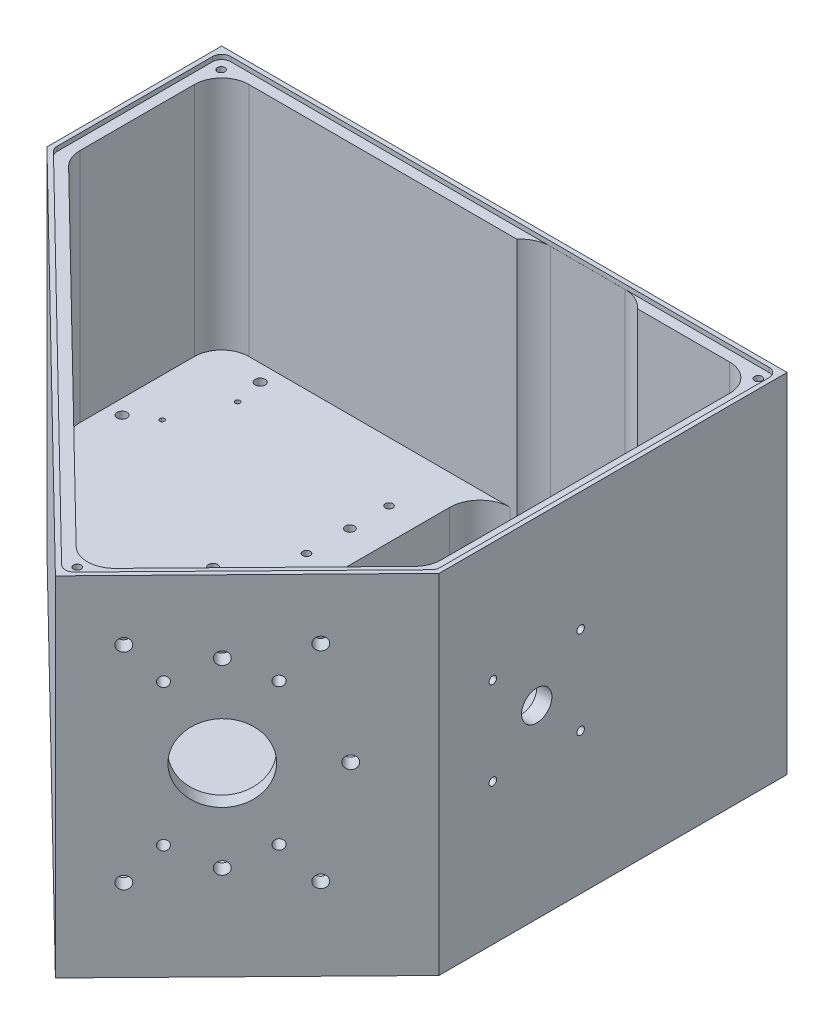
from build123d import *

# Parameters (mm, degrees)
BOSS_EXTRUDE3_DEPTH             = 10
BOSS_EXTRUDE5_DEPTH             = 105
FILLET2_R                       = 9
BOSS_EXTRUDE7_DEPTH             = 25.7
FILLET3_R                       = 10
FILLET4_R                       = 10
CUT_EXTRUDE4_DEPTH              = 1.5
FILLET5_R                       = 3
CUT_EXTRUDE5_DEPTH              = 20
FILLET6_R                       = 10
CUT_EXTRUDE6_REACH              = 188.714
SKETCH13_R                      = 5
M4X0_7_TAPPED_HOLE2_D           = 3.3
M4X0_7_TAPPED_HOLE2_DEPTH       = 5
SM1_TAPPED_HOLE1_D              = 25.4
SM1_TAPPED_HOLE1_DEPTH          = 5
M4X0_7_TAPPED_HOLE1_D           = 3.3
M4X0_7_TAPPED_HOLE1_DEPTH       = 8
M4X0_7_TAPPED_HOLE1_TIP         = 0.991420021
M2X0_4_TAPPED_HOLE1_D           = 1.6
M2X0_4_TAPPED_HOLE1_DEPTH       = 5.2
M2X0_4_TAPPED_HOLE1_TIP         = 0.480688495
M3X0_5_TAPPED_HOLE1_D           = 2.5
M3X0_5_TAPPED_HOLE1_DEPTH       = 7.5
M3X0_5_TAPPED_HOLE1_TIP         = 0.751075774
F_3_0MM_DOWEL_HOLE1_D           = 3
F_3_0MM_DOWEL_HOLE1_DEPTH       = 5.2
F_3_0MM_DOWEL_HOLE1_TIP         = 0.901290929
M3X0_5_TAPPED_HOLE2_D           = 2.5
M3X0_5_TAPPED_HOLE2_DEPTH       = 5
M3X0_5_TAPPED_HOLE3_D           = 2.5
M3X0_5_TAPPED_HOLE3_DEPTH       = 7.5
M3X0_5_TAPPED_HOLE3_TIP         = 0.751075774
F_1_16_0_0625_DOWEL_HOLE1_D     = 1.5875
F_1_16_0_0625_DOWEL_HOLE1_DEPTH = 5.2
F_1_16_0_0625_DOWEL_HOLE1_TIP   = 0.476933116
F_3_0MM_DOWEL_HOLE2_D           = 3
F_3_0MM_DOWEL_HOLE2_DEPTH       = 5.2
F_3_0MM_DOWEL_HOLE2_TIP         = 0.901290929
M3X0_5_TAPPED_HOLE4_D           = 2.5
M3X0_5_TAPPED_HOLE4_DEPTH       = 7.5
M3X0_5_TAPPED_HOLE4_TIP         = 0.751075774
CUT_EXTRUDE7_DEPTH              = 103.5
M5X0_8_TAPPED_HOLE2_D           = 4.2
M5X0_8_TAPPED_HOLE2_DEPTH       = 5
M5X0_8_TAPPED_HOLE3_D           = 4.2
M5X0_8_TAPPED_HOLE3_DEPTH       = 5


with BuildPart() as part:
    # Sketch1 → Boss-Extrude3 (new body)
    with BuildSketch(Plane(origin=(0, 0, 0), x_dir=(1, 0, 0), z_dir=(0, 1, 0))):
        Polygon((-99.454594588, 85.287259619), (-99.454594588, 27.580704883), (24.630684429, -93.704474274), (87.259436127, -29.629818302), (87.259436127, 85.287259619), align=None)
    extrude(amount=BOSS_EXTRUDE3_DEPTH)

    # Sketch6 → Boss-Extrude5 (add)
    with BuildSketch(Plane(origin=(0, 10, 0), x_dir=(1, 0, 0), z_dir=(0, 1, 0))):
        Polygon((-99.454594588, 85.287259619), (-99.454594588, 27.580704883), (24.630684429, -93.704474274), (87.259436127, -29.629818302), (87.259436127, 85.287259619), align=None)
        Polygon((82.259436127, 80.287259619), (-94.454594588, 80.287259619), (-94.454594588, 29.68527495), (24.549996611, -86.63386684), (82.259436127, -27.592094762), align=None, mode=Mode.SUBTRACT)
    extrude(amount=BOSS_EXTRUDE5_DEPTH)

    # Fillet2
    fillet2_edges = [part.edges().sort_by_distance(p)[0] for p in [
        (82.259436127, 62.5, -80.287259619),
        (-94.454594588, 62.5, -80.287259619),
        (-94.454594588, 62.5, -29.68527495),
        (24.549996611, 62.5, 86.63386684),
        (82.259436127, 62.5, 27.592094762),
    ]]
    fillet(fillet2_edges, radius=FILLET2_R)

    # Sketch9 → Boss-Extrude7 (add)
    with BuildSketch(Plane(origin=(0, 10, 0), x_dir=(1, 0, 0), z_dir=(0, 1, 0))):
        Polygon((-9.164109107, 80.287259619), (-9.164109107, 16.274353327), (-44.132452564, -19.501301083), (-96.380135247, 31.56736399), (-96.380135247, 80.287259619), align=None)
    extrude(amount=BOSS_EXTRUDE7_DEPTH)

    # Fillet3
    fillet3_edges = [part.edges().sort_by_distance(p)[0] for p in [
        (-44.132452564, 22.85, 19.501301083),
    ]]
    fillet(fillet3_edges, radius=FILLET3_R)

    # Fillet4
    fillet4_edges = [part.edges().sort_by_distance(p)[0] for p in [
        (-9.164109107, 22.85, -80.287259619),
    ]]
    fillet(fillet4_edges, radius=FILLET4_R)

    # Sketch10 → Cut-Extrude4 (cut)
    with BuildSketch(Plane(origin=(0, 115, 0), x_dir=(1, 0, 0), z_dir=(0, 1, 0))):
        Polygon((-97.954594588, 28.212075903), (24.606478083, -91.583292044), (85.759436127, -29.01850124), (85.759436127, 83.787259619), (-97.954594588, 83.787259619), align=None)
    extrude(amount=-CUT_EXTRUDE4_DEPTH, mode=Mode.SUBTRACT)

    # Fillet5
    fillet5_edges = [part.edges().sort_by_distance(p)[0] for p in [
        (-97.954594588, 114.25, -28.212075903),
        (-97.954594588, 114.25, -83.787259619),
        (85.759436127, 114.25, -83.787259619),
        (85.759436127, 114.25, 29.01850124),
        (24.606478083, 114.25, 91.583292044),
    ]]
    fillet(fillet5_edges, radius=FILLET5_R)

    # Sketch12 → Cut-Extrude5 (cut)
    with BuildSketch(Plane.XZ):
        Polygon((-86.029052321, -30.238498612), (-44.83183875, 10.029061474), (-15.886944756, -19.584080646), (-15.886944756, -74.947835353), (-86.029052321, -74.947835353), align=None)
    extrude(amount=-CUT_EXTRUDE5_DEPTH, mode=Mode.SUBTRACT)

    # Fillet6
    fillet6_edges = [part.edges().sort_by_distance(p)[0] for p in [
        (-86.029052321, 10, -74.947835353),
        (-86.029052321, 10, -30.238498612),
        (-44.83183875, 10, 10.029061474),
        (-15.886944756, 10, -19.584080646),
        (-15.886944756, 10, -74.947835353),
    ]]
    fillet(fillet6_edges, radius=FILLET6_R)

    # Sketch13 → Cut-Extrude6 (cut, up to next)
    with BuildSketch(Plane(origin=(87.259436127, 0, 0), x_dir=(0, 0, -1), z_dir=(1, 0, 0)), mode=Mode.PRIVATE) as cut_extrude6_sk1:
        with Locations((2.612649558, 61.1)):
            Circle(SKETCH13_R)
    cut_extrude6_tool1 = extrude(cut_extrude6_sk1.sketch, amount=-CUT_EXTRUDE6_REACH, mode=Mode.PRIVATE) & part.part
    add(cut_extrude6_tool1.solids().sort_by_distance((87.259436, 61.1, -2.61265))[0], mode=Mode.SUBTRACT)

    # M4x0.7 Tapped Hole2
    with Locations(Plane(origin=(59.436420011, 0, 58.095181851), x_dir=(0.698991962, 0, -0.715129525), z_dir=(0.715129525, 0, 0.698991962))):
        with Locations((2.431115729, 37.767314098), (2.431115729, 84.532685902), (-24.568884271, 84.532685902), (-24.568884271, 37.767314098)):
            Hole(M4X0_7_TAPPED_HOLE2_D / 2, depth=M4X0_7_TAPPED_HOLE2_DEPTH)

    # SM1 Tapped Hole1
    with Locations(Plane(origin=(59.436420011, 0, 58.095181851), x_dir=(0.698991962, 0, -0.715129525), z_dir=(0.715129525, 0, 0.698991962))):
        with Locations((-10.825880291, 61.15)):
            Hole(SM1_TAPPED_HOLE1_D / 2, depth=SM1_TAPPED_HOLE1_DEPTH)

    # M4x0.7 Tapped Hole1
    with Locations(Plane(origin=(0, 35.7, 0), x_dir=(1, 0, 0), z_dir=(0, 1, 0))):
        with Locations((-76.250393956, 74.820995384), (-89.615612831, 42.554502711)):
            Hole(M4X0_7_TAPPED_HOLE1_D / 2, depth=M4X0_7_TAPPED_HOLE1_DEPTH)
            with Locations((0, 0, -(M4X0_7_TAPPED_HOLE1_DEPTH + M4X0_7_TAPPED_HOLE1_TIP / 2))):  # 118° drill point
                Cone(0, M4X0_7_TAPPED_HOLE1_D / 2, M4X0_7_TAPPED_HOLE1_TIP, mode=Mode.SUBTRACT)

    # M2x0.4 Tapped Hole1
    with Locations(Plane(origin=(0, 10, 0), x_dir=(1, 0, 0), z_dir=(0, 1, 0))):
        with Locations((5.789584185, 54.312649558), (25.789584185, 54.312649558), (5.789584185, 34.312649558), (25.789584185, 34.312649558)):
            Hole(M2X0_4_TAPPED_HOLE1_D / 2, depth=M2X0_4_TAPPED_HOLE1_DEPTH)
            with Locations((0, 0, -(M2X0_4_TAPPED_HOLE1_DEPTH + M2X0_4_TAPPED_HOLE1_TIP / 2))):  # 118° drill point
                Cone(0, M2X0_4_TAPPED_HOLE1_D / 2, M2X0_4_TAPPED_HOLE1_TIP, mode=Mode.SUBTRACT)

    # M3x0.5 Tapped Hole1
    with Locations(Plane(origin=(0, 10, 0), x_dir=(1, 0, 0), z_dir=(0, 1, 0))):
        with Locations((53.486513194, 36.740704463), (53.486513194, 17.338730644)):
            Hole(M3X0_5_TAPPED_HOLE1_D / 2, depth=M3X0_5_TAPPED_HOLE1_DEPTH)
            with Locations((0, 0, -(M3X0_5_TAPPED_HOLE1_DEPTH + M3X0_5_TAPPED_HOLE1_TIP / 2))):  # 118° drill point
                Cone(0, M3X0_5_TAPPED_HOLE1_D / 2, M3X0_5_TAPPED_HOLE1_TIP, mode=Mode.SUBTRACT)

    # Ø3.0mm Dowel Hole1
    with Locations(Plane(origin=(0, 10, 0), x_dir=(1, 0, 0), z_dir=(0, 1, 0))):
        with Locations((73.986513194, 2.338730644), (53.486513194, 53.338730644)):
            Hole(F_3_0MM_DOWEL_HOLE1_D / 2, depth=F_3_0MM_DOWEL_HOLE1_DEPTH)
            with Locations((0, 0, -(F_3_0MM_DOWEL_HOLE1_DEPTH + F_3_0MM_DOWEL_HOLE1_TIP / 2))):  # 118° drill point
                Cone(0, F_3_0MM_DOWEL_HOLE1_D / 2, F_3_0MM_DOWEL_HOLE1_TIP, mode=Mode.SUBTRACT)

    # M3x0.5 Tapped Hole2
    with Locations(Plane(origin=(87.259436127, 0, 0), x_dir=(0, 0, -1), z_dir=(1, 0, 0))):
        with Locations((17.112649558, 75.6), (17.112649558, 46.6), (-11.887350442, 46.6), (-11.887350442, 75.6)):
            Hole(M3X0_5_TAPPED_HOLE2_D / 2, depth=M3X0_5_TAPPED_HOLE2_DEPTH)

    # M3x0.5 Tapped Hole3
    with Locations(Plane(origin=(0, 35.7, 0), x_dir=(1, 0, 0), z_dir=(0, 1, 0))):
        with Locations((-19.601854144, 60.718472071), (-19.601854144, 33.456137846)):
            Hole(M3X0_5_TAPPED_HOLE3_D / 2, depth=M3X0_5_TAPPED_HOLE3_DEPTH)
            with Locations((0, 0, -(M3X0_5_TAPPED_HOLE3_DEPTH + M3X0_5_TAPPED_HOLE3_TIP / 2))):  # 118° drill point
                Cone(0, M3X0_5_TAPPED_HOLE3_D / 2, M3X0_5_TAPPED_HOLE3_TIP, mode=Mode.SUBTRACT)

    # 1/16 (0.0625) Dowel Hole1
    with Locations(Plane(origin=(0, 35.7, 0), x_dir=(1, 0, 0), z_dir=(0, 1, 0))):
        with Locations((-81.65008966, 47.846563072), (-74.359970274, 65.446468166)):
            Hole(F_1_16_0_0625_DOWEL_HOLE1_D / 2, depth=F_1_16_0_0625_DOWEL_HOLE1_DEPTH)
            with Locations((0, 0, -(F_1_16_0_0625_DOWEL_HOLE1_DEPTH + F_1_16_0_0625_DOWEL_HOLE1_TIP / 2))):  # 118° drill point
                Cone(0, F_1_16_0_0625_DOWEL_HOLE1_D / 2, F_1_16_0_0625_DOWEL_HOLE1_TIP, mode=Mode.SUBTRACT)

    # Ø3.0mm Dowel Hole2
    with Locations(Plane(origin=(0, 35.7, 0), x_dir=(1, 0, 0), z_dir=(0, 1, 0))):
        with Locations((-19.575203756, 47.747012064), (-31.16172375, 14.167066106)):
            Hole(F_3_0MM_DOWEL_HOLE2_D / 2, depth=F_3_0MM_DOWEL_HOLE2_DEPTH)
            with Locations((0, 0, -(F_3_0MM_DOWEL_HOLE2_DEPTH + F_3_0MM_DOWEL_HOLE2_TIP / 2))):  # 118° drill point
                Cone(0, F_3_0MM_DOWEL_HOLE2_D / 2, F_3_0MM_DOWEL_HOLE2_TIP, mode=Mode.SUBTRACT)

    # M3x0.5 Tapped Hole4
    with Locations(Plane(origin=(0, 113.5, 0), x_dir=(1, 0, 0), z_dir=(0, 1, 0))):
        with Locations((-94.273905994, 79.93319266), (82.766021198, 80.287259619), (24.2404501, -86.105034639)):
            Hole(M3X0_5_TAPPED_HOLE4_D / 2, depth=M3X0_5_TAPPED_HOLE4_DEPTH)
            with Locations((0, 0, -(M3X0_5_TAPPED_HOLE4_DEPTH + M3X0_5_TAPPED_HOLE4_TIP / 2))):  # 118° drill point
                Cone(0, M3X0_5_TAPPED_HOLE4_D / 2, M3X0_5_TAPPED_HOLE4_TIP, mode=Mode.SUBTRACT)

    # Sketch44 → Cut-Extrude7 (cut)
    with BuildSketch(Plane(origin=(0, 113.5, 0), x_dir=(1, 0, 0), z_dir=(0, 1, 0))):
        with BuildLine():
            Line((10.581140502, 83.777152415), (35.2341862, 83.777152415))
            ThreePointArc((35.2341862, 83.777152415), (45.2341862, 73.777152415), (35.2341862, 63.777152415))
            Line((35.2341862, 63.777152415), (10.581140502, 63.777152415))
            ThreePointArc((10.581140502, 63.777152415), (0.581140502, 73.777152415), (10.581140502, 83.777152415))
        make_face()
    extrude(amount=-CUT_EXTRUDE7_DEPTH, mode=Mode.SUBTRACT)

    # M5x0.8 Tapped Hole2
    with Locations(Plane(origin=(59.436420011, 0, 58.095181851), x_dir=(0.698991962, 0, -0.715129525), z_dir=(0.715129525, 0, 0.698991962))):
        with Locations((-10.825880291, 91.15), (-10.825880291, 31.15), (19.174119709, 61.15)):
            Hole(M5X0_8_TAPPED_HOLE2_D / 2, depth=M5X0_8_TAPPED_HOLE2_DEPTH)

    # M5x0.8 Tapped Hole3
    with Locations(Plane(origin=(59.436420011, 0, 58.095181851), x_dir=(0.698991962, 0, -0.715129525), z_dir=(0.715129525, 0, 0.698991962))):
        with Locations((-33.825880291, 95.15), (12.174119709, 95.15), (12.174119709, 27.15), (-33.825880291, 27.15)):
            Hole(M5X0_8_TAPPED_HOLE3_D / 2, depth=M5X0_8_TAPPED_HOLE3_DEPTH)


solid = part.part
